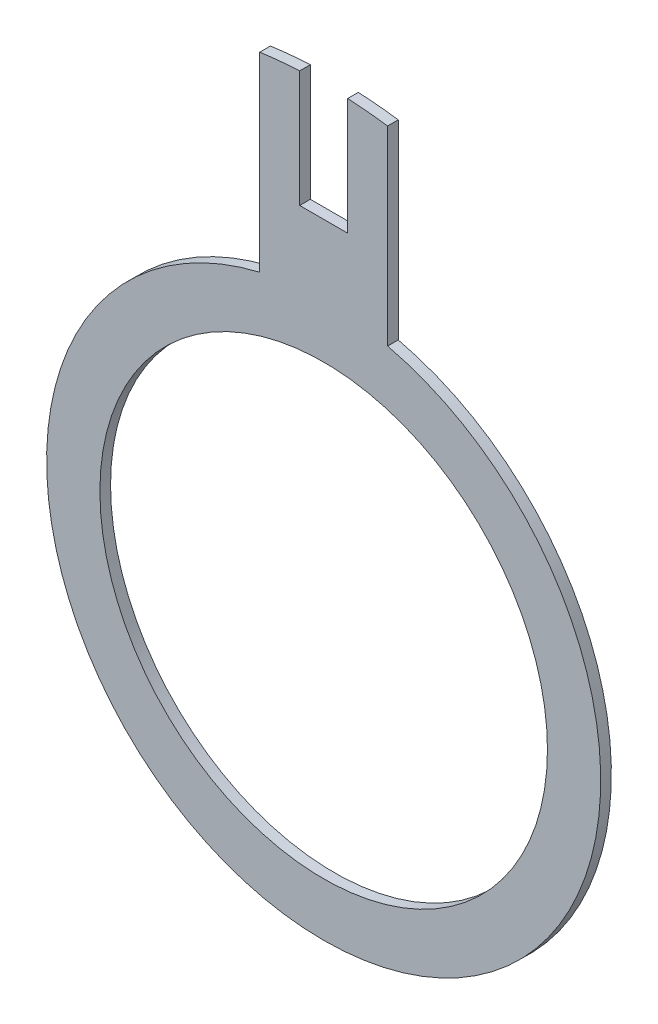
from build123d import *

# Parameters (mm, degrees)
SKETCH1_R           = 2.1
BOSS_EXTRUDE1_DEPTH = 0.1


with BuildPart() as part:
    # Sketch1 → Boss-Extrude1 (new body)
    with BuildSketch(Plane.XY):
        with BuildLine():
            Line((-0.6, 2.529822128), (-0.6, 4.318518264))
            ThreePointArc((-0.6, 4.318518264), (-0.412885429, 4.340406159), (-0.225, 4.35419051))
            Line((-0.225, 4.35419051), (-0.225, 3.26))
            Line((-0.225, 3.26), (0.225, 3.26))
            Line((0.225, 3.26), (0.225, 4.35419051))
            ThreePointArc((0.225, 4.35419051), (0.412885429, 4.340406159), (0.6, 4.318518264))
            Line((0.6, 4.318518264), (0.6, 2.529822128))
            ThreePointArc((0.6, 2.529822128), (0, -2.6), (-0.6, 2.529822128))
        make_face()
        Circle(SKETCH1_R, mode=Mode.SUBTRACT)
    extrude(amount=BOSS_EXTRUDE1_DEPTH)


solid = part.part
